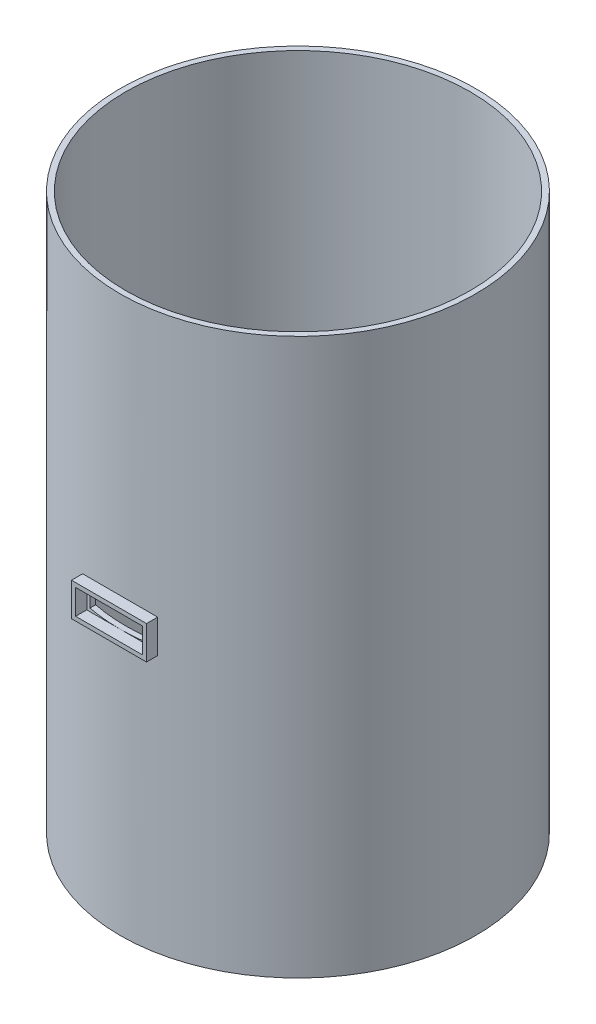
from build123d import *

# Parameters (mm, degrees)
SKETCH1_R               = 32
SKETCH1_R_2             = 31
BOSS_EXTRUDE1_DEPTH     = 100
SKETCH2_W               = 13.5
SKETCH2_H               = 6
SKETCH2_W_2             = 12
SKETCH2_H_2             = 4.5
BOSS_EXTRUDE2_DEPTH     = 2
SKETCH4_W               = 12
SKETCH4_H               = 4.5
CUT_EXTRUDE1_DEPTH      = 3
CUT_EXTRUDE1_DEPTH_BACK = 15


with BuildPart() as part:
    # Sketch1 → Boss-Extrude1 (new body)
    with BuildSketch(Plane(origin=(0, 0, 0), x_dir=(1, 0, 0), z_dir=(0, 1, 0))):
        Circle(SKETCH1_R)
        Circle(SKETCH1_R_2, mode=Mode.SUBTRACT)
    extrude(amount=BOSS_EXTRUDE1_DEPTH)

    # Sketch4 → Cut-Extrude1 (cut, two sides)
    with BuildSketch(Plane.XY.offset(32)) as cut_extrude1_sk:
        with Locations((0, 50)):
            Rectangle(SKETCH4_W, SKETCH4_H)
    extrude(amount=CUT_EXTRUDE1_DEPTH, mode=Mode.SUBTRACT)
    extrude(cut_extrude1_sk.sketch, amount=-CUT_EXTRUDE1_DEPTH_BACK, mode=Mode.SUBTRACT)


with BuildPart() as body_2:
    # Sketch2 → Boss-Extrude2 (new body)
    with BuildSketch(Plane.XY.offset(32)):
        with Locations((0, 50)):
            Rectangle(SKETCH2_W, SKETCH2_H)
        with Locations((0, 50)):
            Rectangle(SKETCH2_W_2, SKETCH2_H_2, mode=Mode.SUBTRACT)
    extrude(amount=BOSS_EXTRUDE2_DEPTH)


solid = Compound([part.part, body_2.part])
